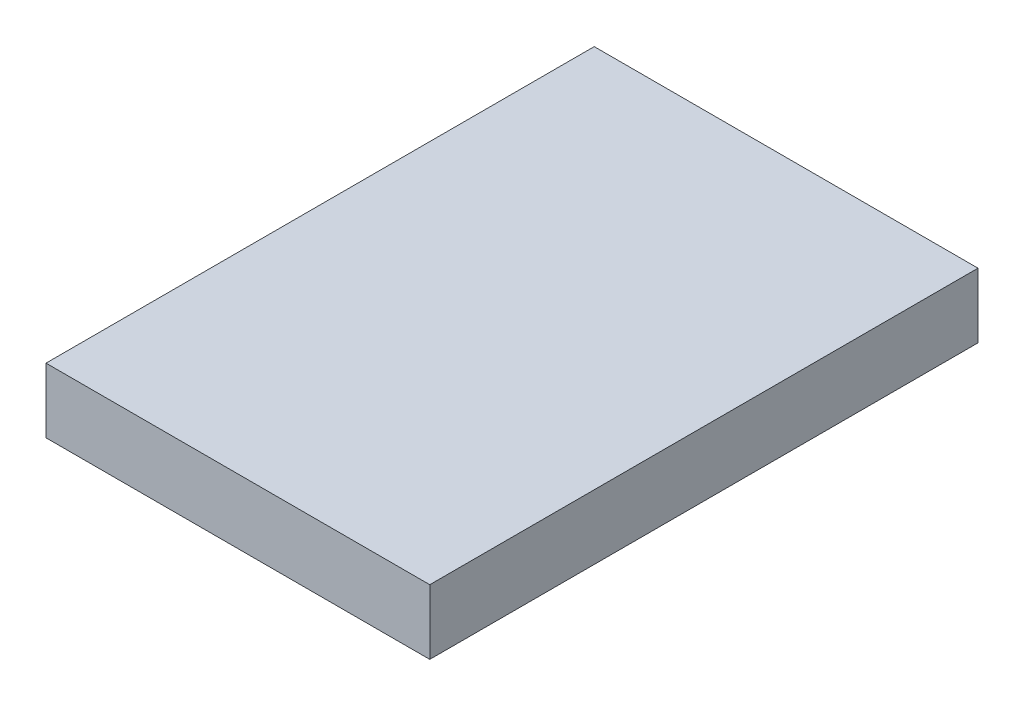
from build123d import *

# Parameters (mm, degrees)
SKETCH1_W           = 14
SKETCH1_H           = 20
BOSS_EXTRUDE1_DEPTH = 2.36


with BuildPart() as part:
    # Sketch1 → Boss-Extrude1 (new body)
    with BuildSketch(Plane(origin=(0, 0, 0), x_dir=(1, 0, 0), z_dir=(0, 1, 0))):
        Rectangle(SKETCH1_W, SKETCH1_H)
    extrude(amount=BOSS_EXTRUDE1_DEPTH)


solid = part.part
